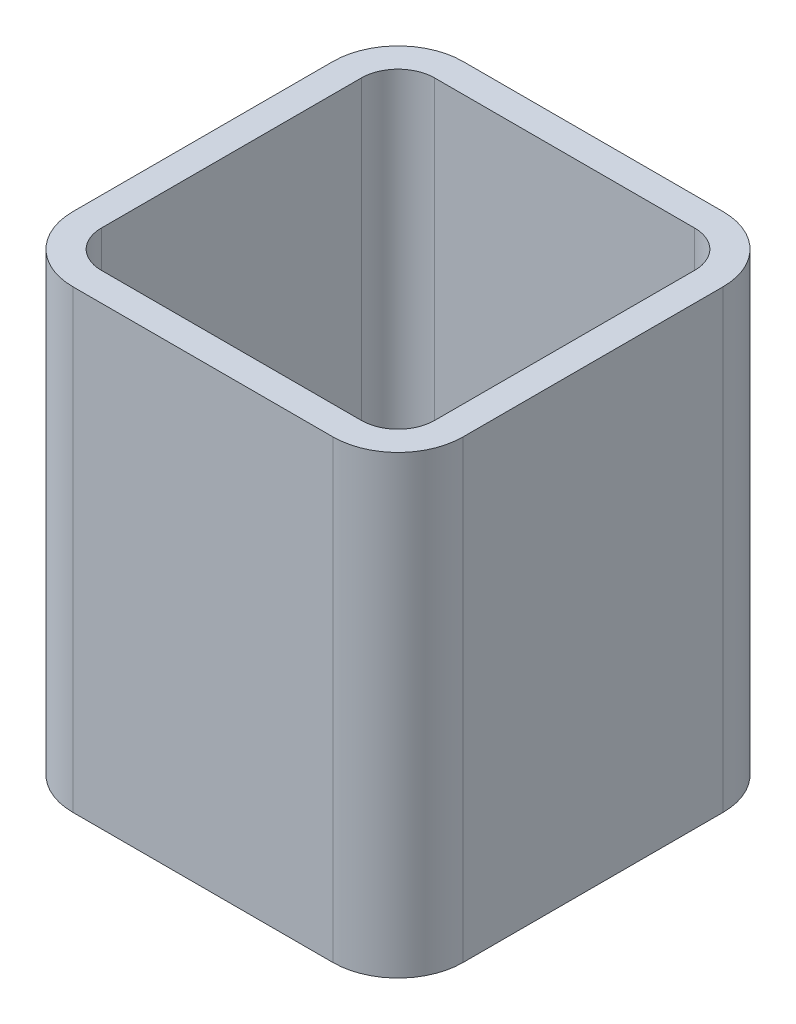
from build123d import *

# Parameters (mm, degrees)
EXTRUDE_THIN1_DEPTH = 355.6


with BuildPart() as part:
    # Sketch2 → Extrude-Thin1 (new body)
    with BuildSketch(Plane(origin=(0, 0, 0), x_dir=(1, 0, 0), z_dir=(0, 1, 0))):
        with BuildLine():
            Line((-101.6, 152.4), (101.6, 152.4))
            ThreePointArc((101.6, 152.4), (137.521024484, 137.521024484), (152.4, 101.6))
            Line((152.4, 101.6), (152.4, -101.6))
            ThreePointArc((152.4, -101.6), (137.521024484, -137.521024484), (101.6, -152.4))
            Line((101.6, -152.4), (-101.6, -152.4))
            ThreePointArc((-101.6, -152.4), (-137.521024484, -137.521024484), (-152.4, -101.6))
            Line((-152.4, -101.6), (-152.4, 101.6))
            ThreePointArc((-152.4, 101.6), (-137.521024484, 137.521024484), (-101.6, 152.4))
        make_face()
        with BuildLine():
            Line((-101.6, 130.175), (101.6, 130.175))
            ThreePointArc((101.6, 130.175), (121.805576272, 121.805576272), (130.175, 101.6))
            Line((130.175, 101.6), (130.175, -101.6))
            ThreePointArc((130.175, -101.6), (121.805576272, -121.805576272), (101.6, -130.175))
            Line((101.6, -130.175), (-101.6, -130.175))
            ThreePointArc((-101.6, -130.175), (-121.805576272, -121.805576272), (-130.175, -101.6))
            Line((-130.175, -101.6), (-130.175, 101.6))
            ThreePointArc((-130.175, 101.6), (-121.805576272, 121.805576272), (-101.6, 130.175))
        make_face(mode=Mode.SUBTRACT)
    extrude(amount=EXTRUDE_THIN1_DEPTH)


solid = part.part
